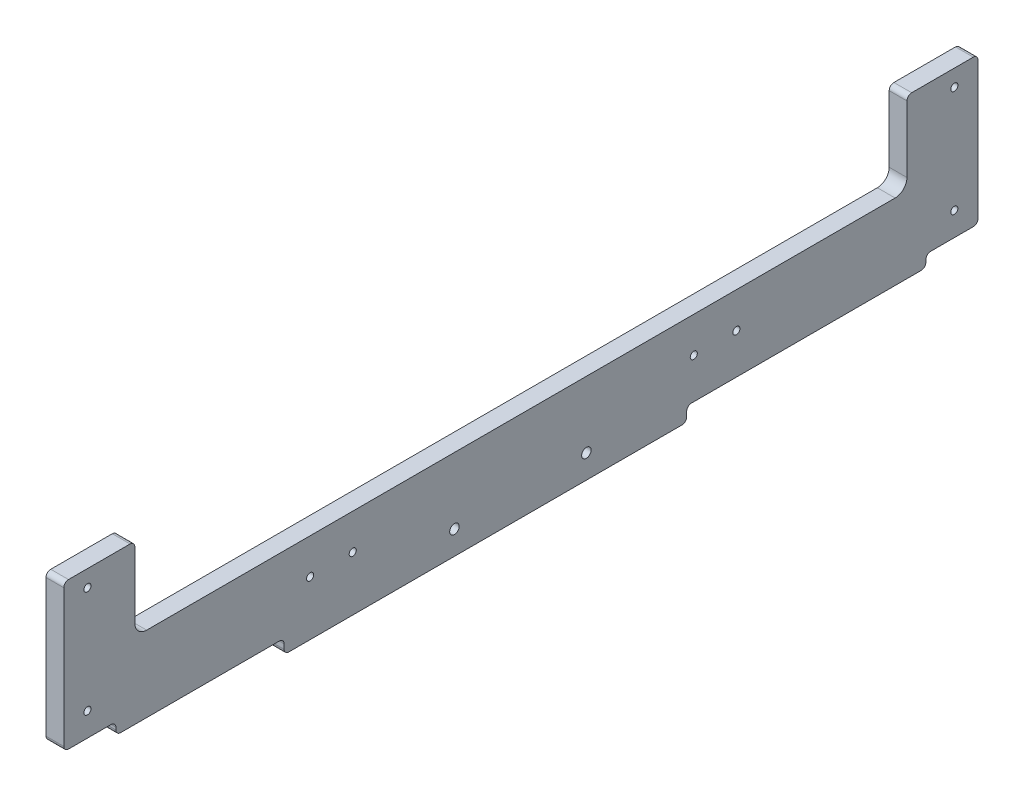
from build123d import *

# Parameters (mm, degrees)
EXTRUDE_1_DEPTH     = 7.5
SKETCH_2_R          = 2
CUT_EXTRUDE_1_DEPTH = 8.5
SKETCH_9_W          = 78
SKETCH_9_H          = 32
SKETCH_9_W_2        = 103
EXTRUDE_3_DEPTH     = 7.5
SKETCH_11_W         = 30
SKETCH_11_H         = 35
EXTRUDE_4_DEPTH     = 7.5
SKETCH_10_R         = 1.5
CUT_EXTRUDE_6_DEPTH = 8.5
FILLET_1_R          = 2
FILLET_3_R          = 5
SKETCH_12_W         = 22
SKETCH_12_H         = 5
CUT_EXTRUDE_7_DEPTH = 8.5
FILLET_4_R          = 2
SKETCH_13_R         = 1.5
CUT_EXTRUDE_8_DEPTH = 8.5


with BuildPart() as part:
    # 草图1 → 凸台-拉伸1 (new body)
    with BuildSketch(Plane(origin=(0, 0, 0), x_dir=(0, 0, -1), z_dir=(1, 0, 0))):
        Polygon((0, 32), (0, 0), (15, 0), (15, -6), (185, -6), (185, 0), (205, 0), (205, 32), align=None)
    extrude(amount=EXTRUDE_1_DEPTH)

    # 草图2 → 切除-拉伸1 (cut, through all)
    with BuildSketch(Plane(origin=(7.5, 0, 0), x_dir=(0, 0, -1), z_dir=(1, 0, 0))):
        with Locations((86.95, 4)):
            Circle(SKETCH_2_R)
        with Locations((142.65, 4)):
            Circle(SKETCH_2_R)
    extrude(amount=-CUT_EXTRUDE_1_DEPTH, mode=Mode.SUBTRACT)

    # 草图9 → 凸台-拉伸3 (add)
    with BuildSketch(Plane(origin=(7.5, 0, 0), x_dir=(0, 0, -1), z_dir=(1, 0, 0))):
        with Locations((-39, 16)):
            Rectangle(SKETCH_9_W, SKETCH_9_H)
        with Locations((256.5, 16)):
            Rectangle(SKETCH_9_W_2, SKETCH_9_H)
    extrude(amount=-EXTRUDE_3_DEPTH)

    # 草图11 → 凸台-拉伸4 (add)
    with BuildSketch(Plane(origin=(7.5, 0, 0), x_dir=(0, 0, -1), z_dir=(1, 0, 0))):
        with Locations((-63, 49.5)):
            Rectangle(SKETCH_11_W, SKETCH_11_H)
        with Locations((293, 49.5)):
            Rectangle(SKETCH_11_W, SKETCH_11_H)
    extrude(amount=-EXTRUDE_4_DEPTH)

    # 草图10 → 切除-拉伸6 (cut, through all)
    with BuildSketch(Plane(origin=(7.5, 0, 0), x_dir=(0, 0, -1), z_dir=(1, 0, 0))):
        with Locations((-68, 15)):
            Circle(SKETCH_10_R)
        with Locations((298, 15)):
            Circle(SKETCH_10_R)
        with Locations((-68, 60)):
            Circle(SKETCH_10_R)
        with Locations((298, 60)):
            Circle(SKETCH_10_R)
    extrude(amount=-CUT_EXTRUDE_6_DEPTH, mode=Mode.SUBTRACT)

    # 圆角1
    fillet_1_edges = [part.edges().sort_by_distance(p)[0] for p in [
        (3.75, 0, -185),
        (3.75, -6, -185),
        (3.75, -6, -15),
        (3.75, 0, -15),
        (3.75, 0, 78),
        (3.75, 0, -308),
        (3.75, 67, 78),
        (3.75, 67, 48),
        (3.75, 67, -308),
        (3.75, 67, -278),
    ]]
    fillet(fillet_1_edges, radius=FILLET_1_R)

    # 圆角3
    fillet_3_edges = [part.edges().sort_by_distance(p)[0] for p in [
        (3.75, 32, 48),
        (3.75, 32, -278),
    ]]
    fillet(fillet_3_edges, radius=FILLET_3_R)

    # 草图12 → 切除-拉伸7 (cut, through all)
    with BuildSketch(Plane(origin=(7.5, 0, 0), x_dir=(0, 0, -1), z_dir=(1, 0, 0))):
        with Locations((-67, 2.5)):
            Rectangle(SKETCH_12_W, SKETCH_12_H)
        with Locations((297, 2.5)):
            Rectangle(SKETCH_12_W, SKETCH_12_H)
    extrude(amount=-CUT_EXTRUDE_7_DEPTH, mode=Mode.SUBTRACT)

    # 圆角4
    fillet_4_edges = [part.edges().sort_by_distance(p)[0] for p in [
        (3.75, 5, 78),
        (3.75, 5, 56),
        (3.75, 0, 56),
        (3.75, 5, -308),
        (3.75, 0, -286),
        (3.75, 5, -286),
    ]]
    fillet(fillet_4_edges, radius=FILLET_4_R)

    # 草图13 → 切除-拉伸8 (cut, through all)
    with BuildSketch(Plane(origin=(7.5, 0, 0), x_dir=(0, 0, -1), z_dir=(1, 0, 0))):
        with Locations((205.999999668, 17.000000039)):
            Circle(SKETCH_13_R)
        with Locations((187.999999668, 17.000000039)):
            Circle(SKETCH_13_R)
        with Locations((43.999999668, 17.000000039)):
            Circle(SKETCH_13_R)
        with Locations((25.999999668, 17.000000039)):
            Circle(SKETCH_13_R)
    extrude(amount=-CUT_EXTRUDE_8_DEPTH, mode=Mode.SUBTRACT)


solid = part.part
